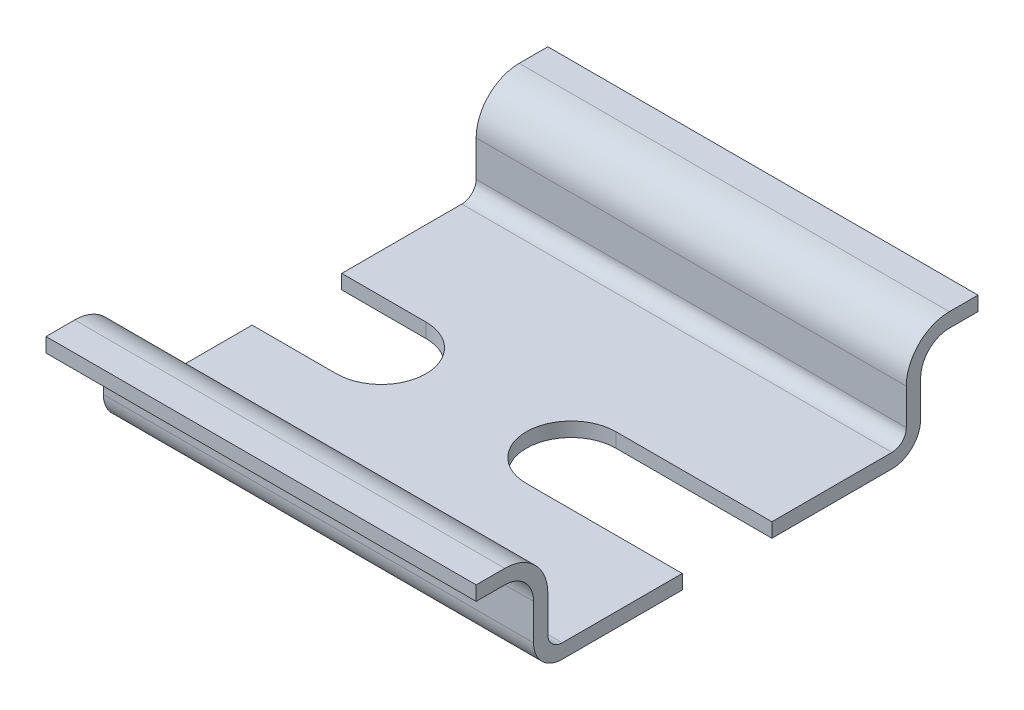
from build123d import *

# Parameters (mm, degrees)
EXTRUDE_THIN1_DEPTH = 30
CUT_EXTRUDE1_DEPTH  = 1
LPATTERN1_COUNT     = 2
LPATTERN1_PITCH     = 25


with BuildPart() as part:
    # Sketch1 → Extrude-Thin1 (new body)
    with BuildSketch(Plane(origin=(0, 0, 0), x_dir=(0, 0, -1), z_dir=(1, 0, 0))):
        with BuildLine():
            Line((-17.5, 6.5), (-15.5, 6.5))
            ThreePointArc((-15.5, 6.5), (-14.085786438, 5.914213562), (-13.5, 4.5))
            Line((-13.5, 4.5), (-13.5, 2))
            ThreePointArc((-13.5, 2), (-12.914213562, 0.585786438), (-11.5, 0))
            Line((-11.5, 0), (11.5, 0))
            ThreePointArc((11.5, 0), (12.914213562, 0.585786438), (13.5, 2))
            Line((13.5, 2), (13.5, 4.5))
            ThreePointArc((13.5, 4.5), (14.085786438, 5.914213562), (15.5, 6.5))
            Line((15.5, 6.5), (17.5, 6.5))
            Line((17.5, 6.5), (17.5, 7.5))
            Line((17.5, 7.5), (15.5, 7.5))
            ThreePointArc((15.5, 7.5), (13.378679656, 6.621320344), (12.5, 4.5))
            Line((12.5, 4.5), (12.5, 2))
            ThreePointArc((12.5, 2), (12.207106781, 1.292893219), (11.5, 1))
            Line((11.5, 1), (-11.5, 1))
            ThreePointArc((-11.5, 1), (-12.207106781, 1.292893219), (-12.5, 2))
            Line((-12.5, 2), (-12.5, 4.5))
            ThreePointArc((-12.5, 4.5), (-13.378679656, 6.621320344), (-15.5, 7.5))
            Line((-15.5, 7.5), (-17.5, 7.5))
            Line((-17.5, 7.5), (-17.5, 6.5))
        make_face()
    extrude(amount=EXTRUDE_THIN1_DEPTH)

    # Sketch2 → Cut-Extrude1 (cut)
    with BuildSketch(Plane.XZ):
        with BuildLine():
            Line((-5.875, 3.125), (5.875, 3.125))
            ThreePointArc((5.875, 3.125), (9, 0), (5.875, -3.125))
            Line((5.875, -3.125), (-5.875, -3.125))
            ThreePointArc((-5.875, -3.125), (-9, 0), (-5.875, 3.125))
        make_face()
    cut_extrude1 = extrude(amount=-CUT_EXTRUDE1_DEPTH, mode=Mode.SUBTRACT)

    # LPattern1: Cut-Extrude1 ×2
    with Locations(*[(i * LPATTERN1_PITCH, 0, 0) for i in range(1, LPATTERN1_COUNT)]):
        add(cut_extrude1, mode=Mode.SUBTRACT)


solid = part.part
